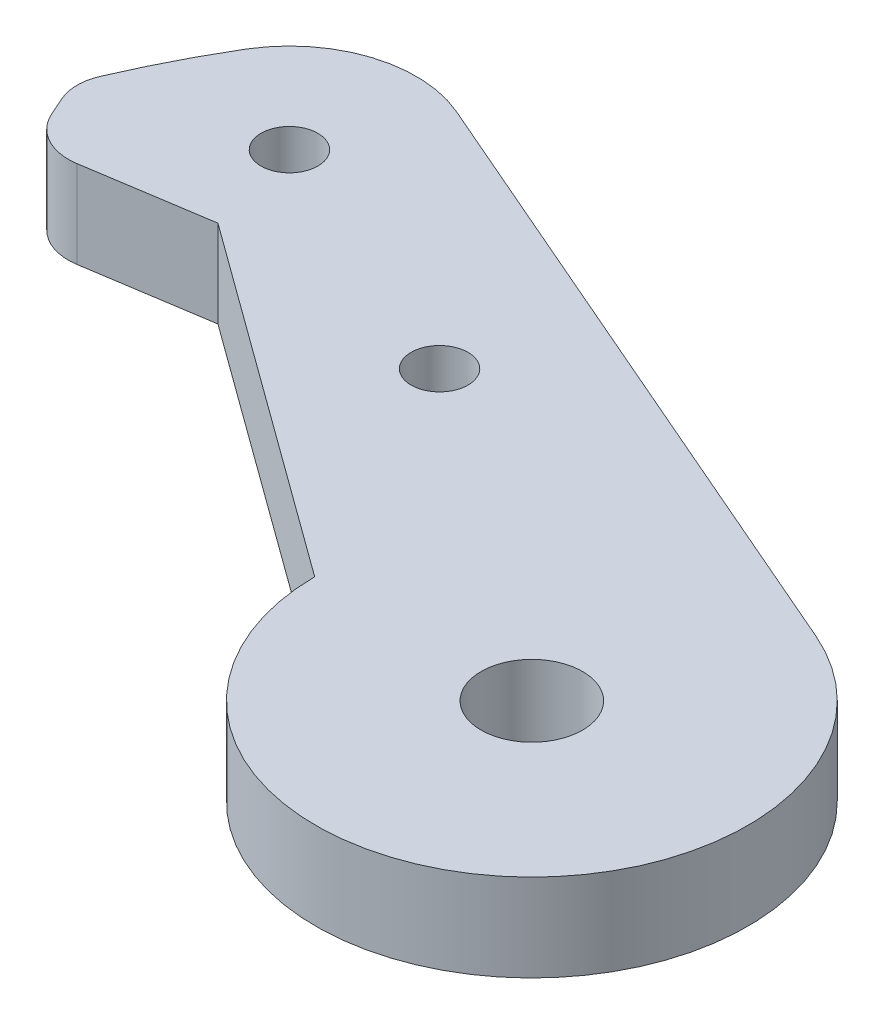
from build123d import *

# Parameters (mm, degrees)
SKETCH1_R           = 1.778
SKETCH1_R_2         = 3.175
BOSS_EXTRUDE1_DEPTH = 5.461


with BuildPart() as part:
    # Sketch1 → Boss-Extrude1 (new body)
    with BuildSketch(Plane(origin=(0, 0, 0), x_dir=(1, 0, 0), z_dir=(0, 1, 0))):
        with BuildLine():
            Line((-35.671169379, 16.048164087), (-13.499793526, -0.074664302))
            ThreePointArc((-13.499793526, -0.074664302), (7.44200849, -11.263503435), (5.363638877, 12.388760148))
            Line((5.363638877, 12.388760148), (-34.259632886, 29.543416329))
            ThreePointArc((-34.259632886, 29.543416329), (-39.855484626, 29.811728531), (-44.234733225, 26.317772344))
            ThreePointArc((-44.234733225, 26.317772344), (-45.865213893, 23.360627542), (-47.298283286, 20.302934833))
            ThreePointArc((-47.298283286, 20.302934833), (-47.541465806, 19.100109045), (-47.282683039, 17.900542834))
            Line((-47.282683039, 17.900542834), (-46.773518475, 16.755633062))
            ThreePointArc((-46.773518475, 16.755633062), (-45.359998522, 15.22299407), (-43.306077078, 14.864626044))
            Line((-43.306077078, 14.864626044), (-35.671169379, 16.048164087))
        make_face()
        with Locations((-20.862458922, 15.093717491)):
            Circle(SKETCH1_R, mode=Mode.SUBTRACT)
        Circle(SKETCH1_R_2, mode=Mode.SUBTRACT)
        with Locations((-37.413253893, 22.259284205)):
            Circle(SKETCH1_R, mode=Mode.SUBTRACT)
    extrude(amount=BOSS_EXTRUDE1_DEPTH)


solid = part.part
